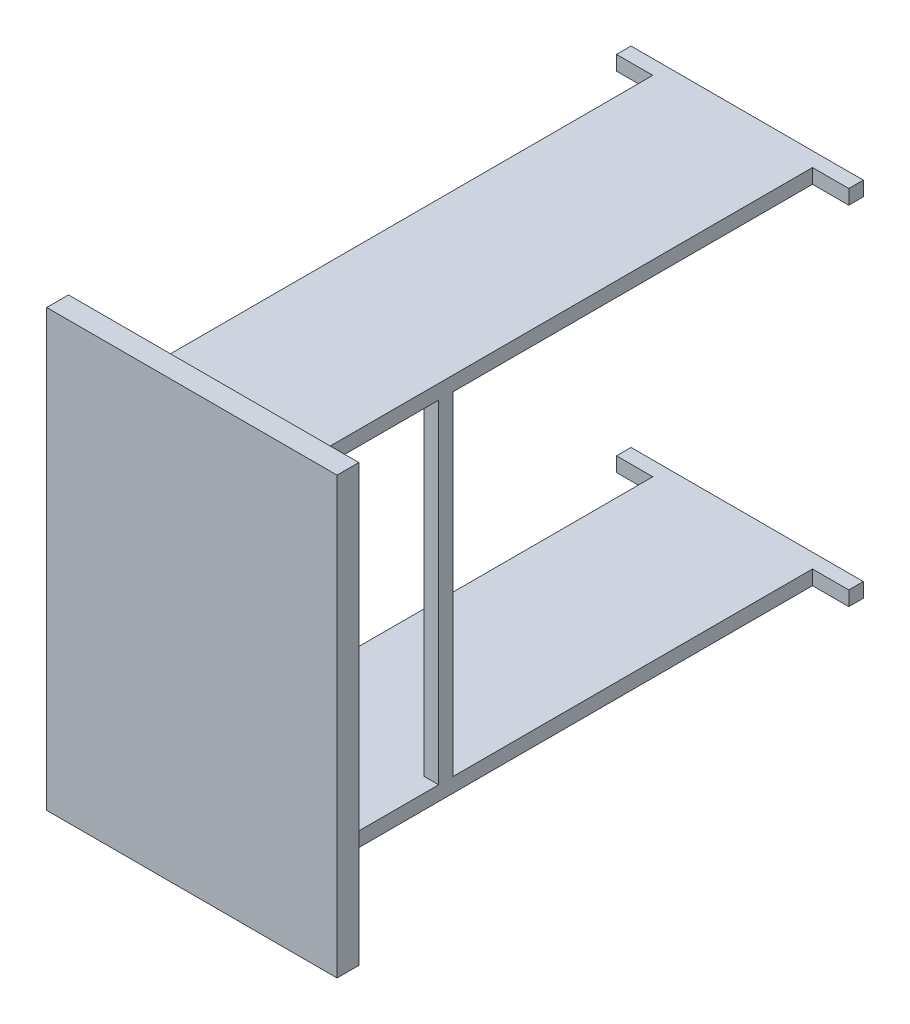
from build123d import *

# Parameters (mm, degrees)
CROQUIS1_W              = 400
CROQUIS1_H              = 600
SALIENTE_EXTRUIR1_DEPTH = 30
CROQUIS3_W              = 320
CROQUIS3_H              = 20
SALIENTE_EXTRUIR2_DEPTH = 735
CROQUIS4_W              = 50
CROQUIS4_H              = 695
CORTAR_EXTRUIR1_DEPTH   = 550.471728
CROQUIS5_W              = 20
CROQUIS5_H              = 20
SALIENTE_EXTRUIR3_DEPTH = 458.943456


with BuildPart() as part:
    # Croquis1 → Saliente-Extruir1 (new body)
    with BuildSketch(Plane.XY):
        Rectangle(CROQUIS1_W, CROQUIS1_H)
    extrude(amount=SALIENTE_EXTRUIR1_DEPTH)

    # Croquis3 → Saliente-Extruir2 (add)
    with BuildSketch(Plane(origin=(0, 0, 0), x_dir=(-1, 0, 0), z_dir=(0, 0, -1))):
        with Locations((0, 239.471728)):
            Rectangle(CROQUIS3_W, CROQUIS3_H)
    saliente_extruir2 = extrude(amount=SALIENTE_EXTRUIR2_DEPTH)

    # Simetría1: Saliente-Extruir2 across plane
    add(saliente_extruir2.mirror(Plane.ZX))

    # Croquis4 → Cortar-Extruir1 (cut, through all)
    with BuildSketch(Plane.XZ.offset(249.471728)):
        with Locations((-135, -367.5)):
            Rectangle(CROQUIS4_W, CROQUIS4_H)
        with Locations((135, -367.5)):
            Rectangle(CROQUIS4_W, CROQUIS4_H)
    extrude(amount=-CORTAR_EXTRUIR1_DEPTH, mode=Mode.SUBTRACT)

    # Croquis5 → Saliente-Extruir3 (add)
    with BuildSketch(Plane.XZ.offset(-229.471728)):
        with Locations((-100, -210)):
            Rectangle(CROQUIS5_W, CROQUIS5_H)
    saliente_extruir3 = extrude(amount=SALIENTE_EXTRUIR3_DEPTH)

    # Simetría2: Saliente-Extruir3 across plane
    add(saliente_extruir3.mirror(Plane(origin=(0, 0, 0), x_dir=(0, 0, 1), z_dir=(1, 0, 0))))


solid = part.part
